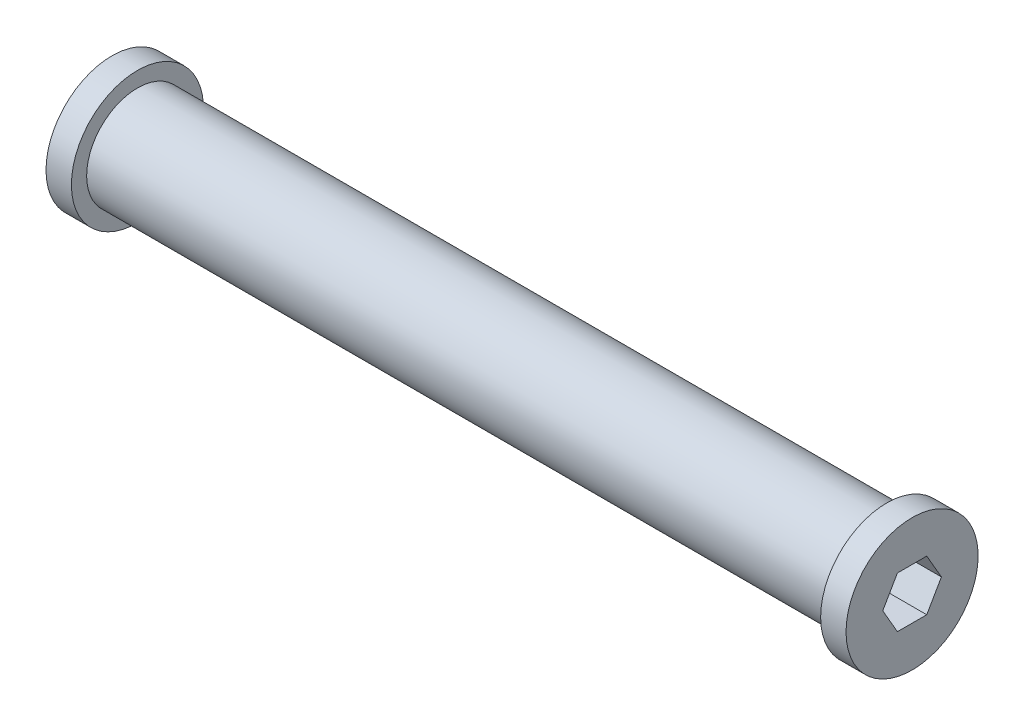
from build123d import *

# Parameters (mm, degrees)
CUT_EXTRUDE1_DEPTH = 201


with BuildPart() as part:
    # Sketch1 → Revolve1 (revolve)
    with BuildSketch(Plane.XY):
        Polygon((-100, 6.35), (100, 6.35), (100, 16.51), (93.65, 16.51), (93.65, 12.7), (-93.65, 12.7), (-93.65, 16.51), (-100, 16.51), align=None)
    revolve(axis=Axis((0, 0, 0), (1, 0, 0)))

    # Sketch2 → Cut-Extrude1 (cut, through all)
    with BuildSketch(Plane(origin=(100, 0, 0), x_dir=(0, 0, -1), z_dir=(1, 0, 0))):
        Polygon((3.666174209, 6.35), (-3.666174209, 6.35), (-7.332348419, 0), (-3.666174209, -6.35), (3.666174209, -6.35), (7.332348419, 0), align=None)
    extrude(amount=-CUT_EXTRUDE1_DEPTH, mode=Mode.SUBTRACT)


solid = part.part
